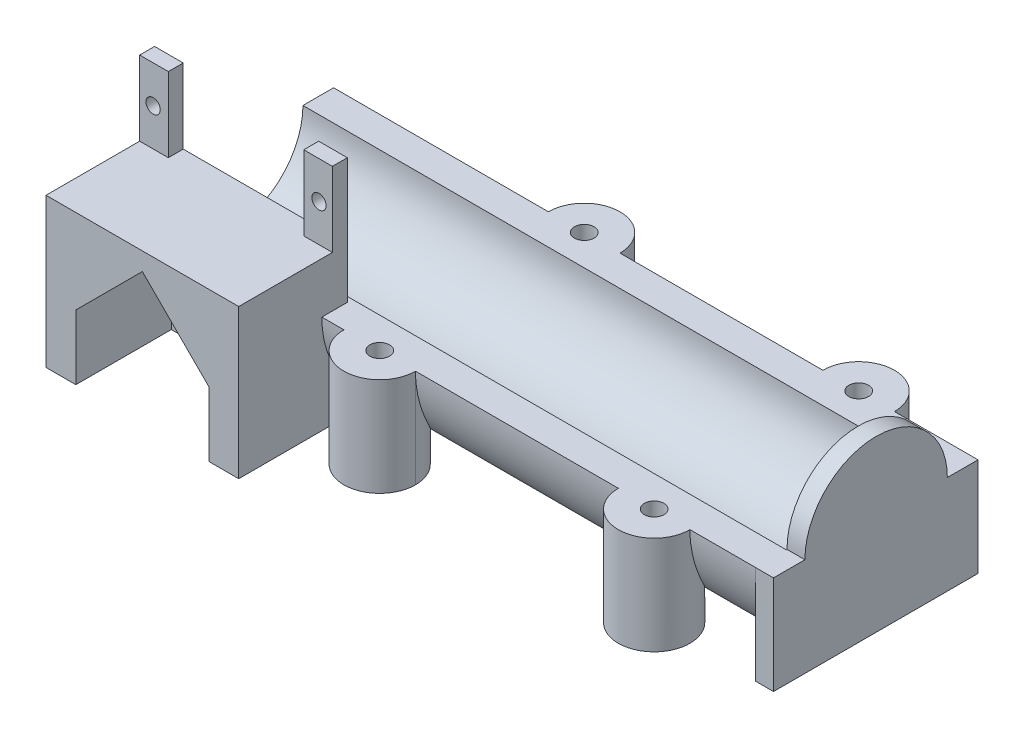
from build123d import *

# Parameters (mm, degrees)
SKETCH1_R           = 1.2
BOSS_EXTRUDE1_DEPTH = 2.5
SKETCH2_W           = 32.3
SKETCH2_H           = 25
BOSS_EXTRUDE2_DEPTH = 15.7
BOSS_EXTRUDE3_DEPTH = 105
BOSS_EXTRUDE4_START = 105
BOSS_EXTRUDE4_DEPTH = 3
BOSS_EXTRUDE5_DEPTH = 16.502469
SKETCH8_R           = 1.65
CUT_EXTRUDE1_DEPTH  = 46.267987394
CUT_EXTRUDE2_START  = 11
CUT_EXTRUDE2_DEPTH  = 2.6
CUT_EXTRUDE3_DEPTH  = 16


with BuildPart() as part:
    # Sketch1 → Boss-Extrude1 (new body)
    with BuildSketch(Plane.XY):
        Polygon((0, 0), (0, 37.5), (4.8, 37.5), (4.8, 25), (27.5, 25), (27.5, 37.5), (32.3, 37.5), (32.3, 0), align=None)
        with Locations((2.25, 31.25)):
            Circle(SKETCH1_R, mode=Mode.SUBTRACT)
        with Locations((30.05, 31.25)):
            Circle(SKETCH1_R, mode=Mode.SUBTRACT)
    extrude(amount=BOSS_EXTRUDE1_DEPTH)

    # Sketch2 → Boss-Extrude2 (add)
    with BuildSketch(Plane.XY.offset(2.5)):
        with Locations((16.15, 12.5)):
            Rectangle(SKETCH2_W, SKETCH2_H)
    extrude(amount=BOSS_EXTRUDE2_DEPTH)

    # Sketch4 → Boss-Extrude3 (add)
    with BuildSketch(Plane(origin=(0, 0, 0), x_dir=(0, 0, -1), z_dir=(1, 0, 0))):
        with BuildLine():
            ThreePointArc((-4.272382365, 16.502469348), (-0.788451938, 6.145596051), (8.24671518, 0))
            Line((8.24671518, 0), (17.480902455, 0))
            ThreePointArc((17.480902455, 0), (26.516069574, 6.145596051), (30, 16.502469348))
            Line((30, 16.502469348), (24.863808818, 16.502469348))
            ThreePointArc((24.863808818, 16.502469348), (12.863808818, 4.502469348), (0.863808818, 16.502469348))
            Line((0.863808818, 16.502469348), (-4.272382365, 16.502469348))
        make_face()
    extrude(amount=BOSS_EXTRUDE3_DEPTH)

    # Sketch5 → Boss-Extrude4 (add)
    with BuildSketch(Plane(origin=(0, 0, 0), x_dir=(0, 0, -1), z_dir=(1, 0, 0)).offset(BOSS_EXTRUDE4_START)):
        with BuildLine():
            Line((24.863808818, 16.502469348), (30, 16.502469348))
            Line((30, 16.502469348), (30, 0))
            Line((30, 0), (-4.276191182, 0))
            Line((-4.276191182, 0), (-4.276191182, 16.502469348))
            Line((-4.276191182, 16.502469348), (0.988808818, 16.502469348))
            ThreePointArc((0.988808818, 16.502469348), (12.926308818, 28.439969348), (24.863808818, 16.502469348))
        make_face()
    extrude(amount=BOSS_EXTRUDE4_DEPTH)

    # Sketch6 → Boss-Extrude5 (add)
    with BuildSketch(Plane(origin=(0, 16.502469348, 0), x_dir=(1, 0, 0), z_dir=(0, 1, 0))):
        with BuildLine():
            ThreePointArc((48, 30), (42, 36), (36, 30))
            Line((36, 30), (48, 30))
        make_face()
        with BuildLine():
            ThreePointArc((36, 30), (36.774618191, 27.051206187), (38.89846165, 24.863808818))
            Line((38.89846165, 24.863808818), (45.10153835, 24.863808818))
            ThreePointArc((45.10153835, 24.863808818), (47.225381809, 27.051206187), (48, 30))
            Line((48, 30), (36, 30))
        make_face()
        with BuildLine():
            ThreePointArc((45.098382452, 0.863808818), (47.224007714, -1.323058877), (48, -4.272382365))
            ThreePointArc((48, -4.272382365), (42.001904409, -10.272382062), (36.000001209, -4.276191181))
            ThreePointArc((36.000001209, -4.276191181), (36.775057034, -1.324717133), (38.901618757, 0.863808818))
            Line((38.901618757, 0.863808818), (45.098382452, 0.863808818))
        make_face()
        with BuildLine():
            ThreePointArc((91.095222125, 0.863808818), (93.223568356, -1.324186164), (94, -4.276191182))
            ThreePointArc((94, -4.276191182), (88, -10.276191182), (82, -4.276191182))
            ThreePointArc((82, -4.276191182), (82.776431644, -1.324186164), (84.904777875, 0.863808818))
            Line((84.904777875, 0.863808818), (91.095222125, 0.863808818))
        make_face()
        with BuildLine():
            ThreePointArc((94, 30), (88, 36), (82, 30))
            Line((82, 30), (94, 30))
        make_face()
        with BuildLine():
            ThreePointArc((82, 30), (82.774618191, 27.051206187), (84.89846165, 24.863808818))
            Line((84.89846165, 24.863808818), (91.10153835, 24.863808818))
            ThreePointArc((91.10153835, 24.863808818), (93.225381809, 27.051206187), (94, 30))
            Line((94, 30), (82, 30))
        make_face()
    extrude(amount=-BOSS_EXTRUDE5_DEPTH)

    # Sketch8 → Cut-Extrude1 (cut, through all)
    with BuildSketch(Plane(origin=(19.547405665, 45.267987294, 23.856702342), x_dir=(-1, 0, 0), z_dir=(0, 1, 0))):
        with Locations((-68.452594335, -19.58051116)):
            Circle(SKETCH8_R)
        with Locations((-22.452594335, -19.584319977)):
            Circle(SKETCH8_R)
        with Locations((-22.452594335, -53.856702342)):
            Circle(SKETCH8_R)
        with Locations((-68.452594335, -53.856702342)):
            Circle(SKETCH8_R)
    extrude(amount=-CUT_EXTRUDE1_DEPTH, mode=Mode.SUBTRACT)

    # Sketch9 → Cut-Extrude2 (cut)
    with BuildSketch(Plane(origin=(0, 0, 0), x_dir=(1, 0, 0), z_dir=(0, 1, 0)).offset(CUT_EXTRUDE2_START)):
        Polygon((45.348631561, 30), (43.674315781, 32.9), (40.325684219, 32.9), (38.651368439, 30), (40.325684219, 27.1), (43.674315781, 27.1), align=None)
        Polygon((91.348631561, 30), (89.674315781, 32.9), (86.325684219, 32.9), (84.651368439, 30), (86.325684219, 27.1), (89.674315781, 27.1), align=None)
        Polygon((45.348629319, -4.276258001), (43.677671059, -1.374322125), (40.32904174, -1.370446489), (38.651370681, -4.268506728), (40.322328941, -7.170442604), (43.67095826, -7.17431824), align=None)
        Polygon((91.348631561, -4.276191182), (89.674315781, -1.376191182), (86.325684219, -1.376191182), (84.651368439, -4.276191182), (86.325684219, -7.176191182), (89.674315781, -7.176191182), align=None)
    extrude(amount=CUT_EXTRUDE2_DEPTH, mode=Mode.SUBTRACT)

    # Sketch10 → Cut-Extrude3 (cut)
    with BuildSketch(Plane.XY.offset(18.2)):
        Polygon((5, 0), (27.3, 0), (27.3, 10.85), (16.15, 22), (5, 10.85), align=None)
    extrude(amount=-CUT_EXTRUDE3_DEPTH, mode=Mode.SUBTRACT)


solid = part.part
